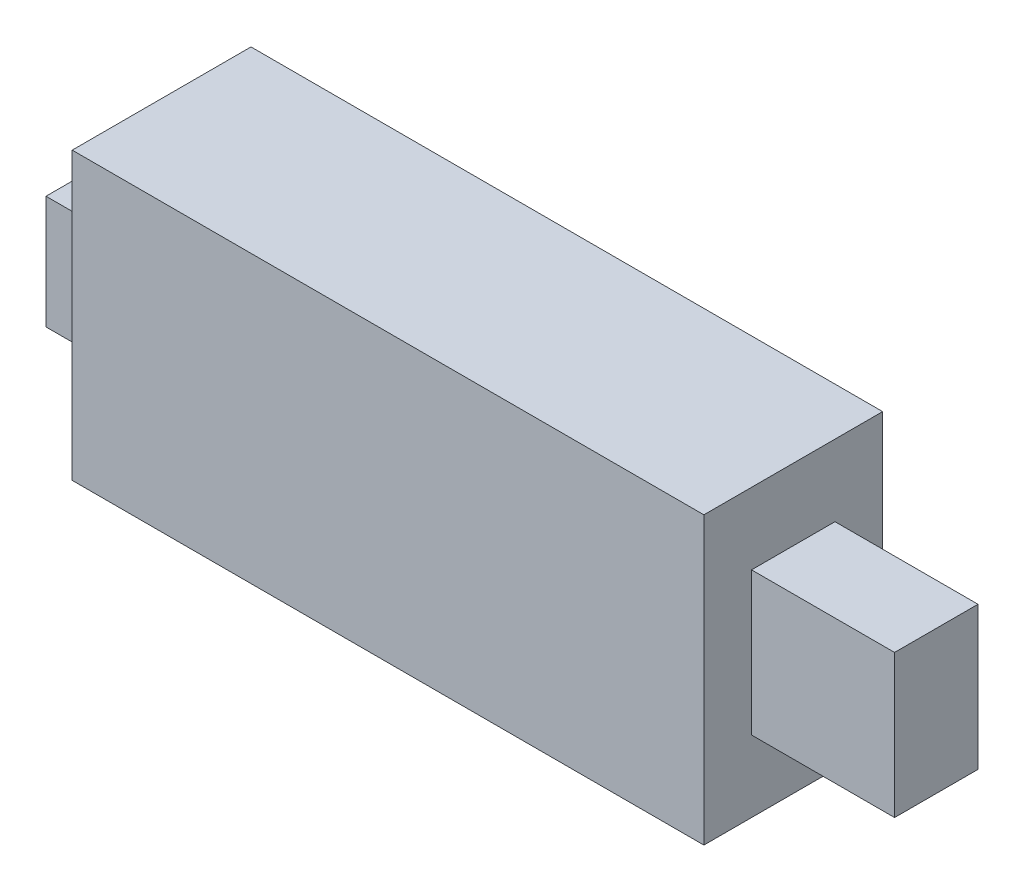
from build123d import *

# Parameters (mm, degrees)
SKETCH_1_W      = 53
SKETCH_1_H      = 24
EXTRUDE_1_DEPTH = 15
SKETCH_2_W      = 7
SKETCH_2_H      = 12
EXTRUDE_2_DEPTH = 12
SKETCH_3_W      = 9.4
SKETCH_3_H      = 9.5
EXTRUDE_3_DEPTH = 5


with BuildPart() as part:
    # 草图1 → 凸台-拉伸1 (new body)
    with BuildSketch(Plane.XY):
        Rectangle(SKETCH_1_W, SKETCH_1_H)
    extrude(amount=EXTRUDE_1_DEPTH)

    # 草图2 → 凸台-拉伸2 (add)
    with BuildSketch(Plane(origin=(26.5, 0, 0), x_dir=(0, 0, -1), z_dir=(1, 0, 0))):
        with Locations((-7.5, 0)):
            Rectangle(SKETCH_2_W, SKETCH_2_H)
    extrude(amount=EXTRUDE_2_DEPTH)

    # 草图3 → 凸台-拉伸3 (add)
    with BuildSketch(Plane.ZY.offset(26.5)):
        with Locations((7.5, 0)):
            Rectangle(SKETCH_3_W, SKETCH_3_H)
    extrude(amount=EXTRUDE_3_DEPTH)


solid = part.part
